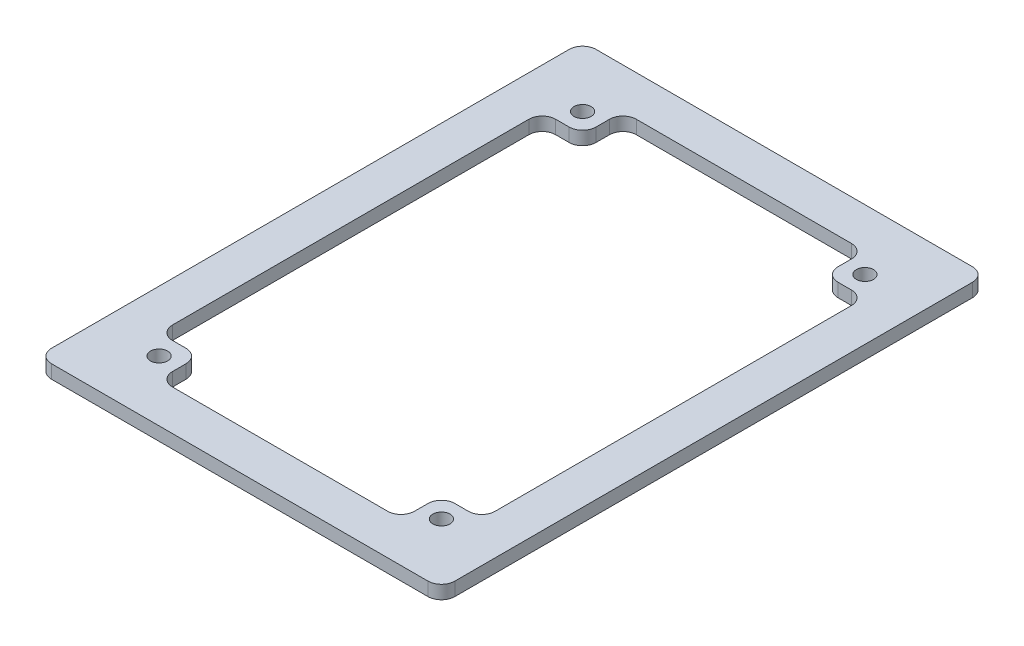
from build123d import *

# Parameters (mm, degrees)
SKETCH_1_W          = 48
SKETCH_1_H          = 69
EXTRUDE_1_DEPTH     = 2
SKETCH_2_W          = 60
SKETCH_2_H          = 81
EXTRUDE_2_DEPTH     = 2
SKETCH_3_W          = 48
SKETCH_3_H          = 69
CUT_EXTRUDE_1_DEPTH = 2
SKETCH_4_W          = 6
SKETCH_4_H          = 6
EXTRUDE_3_DEPTH     = 2
SKETCH_5_R          = 1.275
CUT_EXTRUDE_2_DEPTH = 2
FILLET_1_R          = 2


with BuildPart() as part:
    # 草图1 → 凸台-拉伸1 (new body)
    with BuildSketch(Plane(origin=(0, 0, 0), x_dir=(1, 0, 0), z_dir=(0, 1, 0))):
        Rectangle(SKETCH_1_W, SKETCH_1_H)
    extrude(amount=EXTRUDE_1_DEPTH)

    # 草图2 → 凸台-拉伸2 (add)
    with BuildSketch(Plane(origin=(0, 2, 0), x_dir=(1, 0, 0), z_dir=(0, 1, 0))):
        Rectangle(SKETCH_2_W, SKETCH_2_H)
    extrude(amount=-EXTRUDE_2_DEPTH)

    # 草图3 → 切除-拉伸1 (cut)
    with BuildSketch(Plane(origin=(0, 2, 0), x_dir=(1, 0, 0), z_dir=(0, 1, 0))):
        Rectangle(SKETCH_3_W, SKETCH_3_H)
    extrude(amount=-CUT_EXTRUDE_1_DEPTH, mode=Mode.SUBTRACT)

    # 草图4 → 凸台-拉伸3 (add)
    with BuildSketch(Plane.XZ):
        with Locations((-21, 31.5)):
            Rectangle(SKETCH_4_W, SKETCH_4_H)
        with Locations((21, 31.5)):
            Rectangle(SKETCH_4_W, SKETCH_4_H)
        with Locations((-21, -31.5)):
            Rectangle(SKETCH_4_W, SKETCH_4_H)
        with Locations((21, -31.5)):
            Rectangle(SKETCH_4_W, SKETCH_4_H)
    extrude(amount=-EXTRUDE_3_DEPTH)

    # 草图5 → 切除-拉伸2 (cut)
    with BuildSketch(Plane.XZ):
        with Locations((-21, 31.5)):
            Circle(SKETCH_5_R)
        with Locations((-21, -31.5)):
            Circle(SKETCH_5_R)
        with Locations((21, -31.5)):
            Circle(SKETCH_5_R)
        with Locations((21, 31.5)):
            Circle(SKETCH_5_R)
    extrude(amount=-CUT_EXTRUDE_2_DEPTH, mode=Mode.SUBTRACT)

    # 圆角1
    fillet_1_edges = [part.edges().sort_by_distance(p)[0] for p in [
        (30, 1, -40.5),
        (-30, 1, -40.5),
        (-30, 1, 40.5),
        (30, 1, 40.5),
        (-24, 1, 28.5),
        (-18, 1, 34.5),
        (-18, 1, 28.5),
        (24, 1, 28.5),
        (18, 1, 28.5),
        (18, 1, 34.5),
        (-24, 1, -28.5),
        (-18, 1, -28.5),
        (-18, 1, -34.5),
        (24, 1, -28.5),
        (18, 1, -34.5),
        (18, 1, -28.5),
    ]]
    fillet(fillet_1_edges, radius=FILLET_1_R)


solid = part.part
